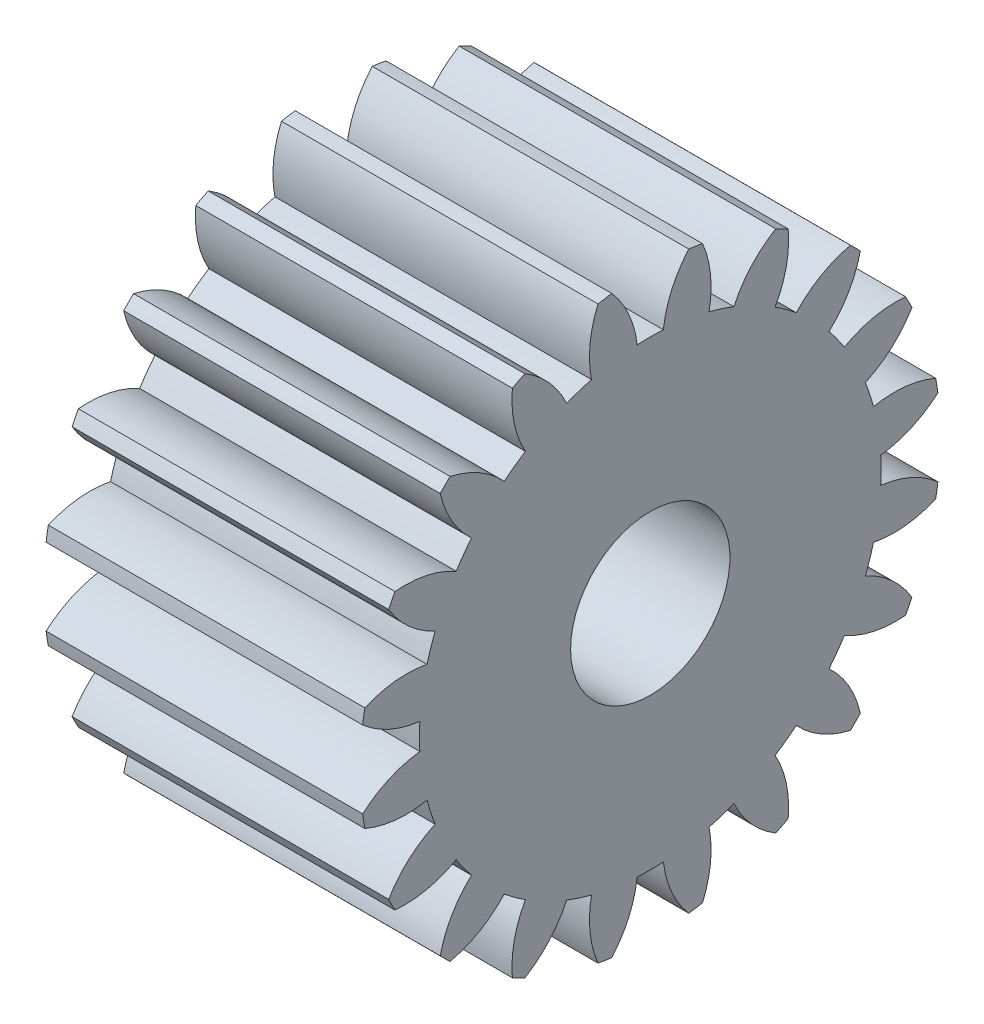
from build123d import *

# Parameters (mm, degrees)
BASPROSKE_W     = 30
BASPROSKE_H     = 27.5
TOOTHCUT_DEPTH  = 50.117206761
TEETHCUTS_COUNT = 20
TEETHCUTS_ANGLE = 342
BORSKE_R        = 7.55
BORE_DEPTH      = 50.000508
SCALE1_SCALE    = 0.8


with BuildPart() as part:
    # BasProSke → Base-Revolve (revolve)
    with BuildSketch(Plane(origin=(0, 0, 0), x_dir=(1, 0, 0), z_dir=(0, 1, 0)), mode=Mode.PRIVATE) as base_revolve_sk:
        with Locations((15, 13.75)):
            Rectangle(BASPROSKE_W, BASPROSKE_H)
    revolve(base_revolve_sk.sketch.rotate(Axis((-10, 0, 0), (1, 0, 0)), 180), axis=Axis((-10, 0, 0), (1, 0, 0)))

    # TooCutSke → ToothCut (cut, through all)
    with BuildSketch(Plane(origin=(0, 0, 0), x_dir=(0, 0, -1), z_dir=(1, 0, 0))):
        with BuildLine():
            ThreePointArc((1.237725267, 21.838954008), (0, 21.874), (-1.237725267, 21.838954008))
            ThreePointArc((-1.237725267, 21.838954008), (-2.095118569, 24.870704072), (-3.853229952, 27.485216662))
            ThreePointArc((-3.853229952, 27.485216662), (0, 27.754), (3.853229952, 27.485216662))
            ThreePointArc((3.853229952, 27.485216662), (2.095118569, 24.870704072), (1.237725267, 21.838954008))
        make_face()
    toothcut = extrude(amount=TOOTHCUT_DEPTH, mode=Mode.SUBTRACT)

    # TeethCuts: ToothCut ×20 about axis
    teethcuts_axis = Axis((-10, 0, 0), (1, 0, 0))
    for i in range(1, TEETHCUTS_COUNT):
        add(toothcut.rotate(teethcuts_axis, i * TEETHCUTS_ANGLE / (TEETHCUTS_COUNT - 1)), mode=Mode.SUBTRACT)

    # BorSke → Bore (cut, symmetric)
    with BuildSketch(Plane(origin=(0, 0, 0), x_dir=(0, 0, -1), z_dir=(1, 0, 0))):
        with Locations(Location((0, 0, 0), (0, 0, 180))):
            Circle(BORSKE_R)
    extrude(amount=BORE_DEPTH, both=True, mode=Mode.SUBTRACT)


with BuildPart() as part_1:
    # Scale1: scaled about (15, 0, 0)
    add(part.part.scale(SCALE1_SCALE).moved(Location((3, 0, 0))))


solid = part_1.part
